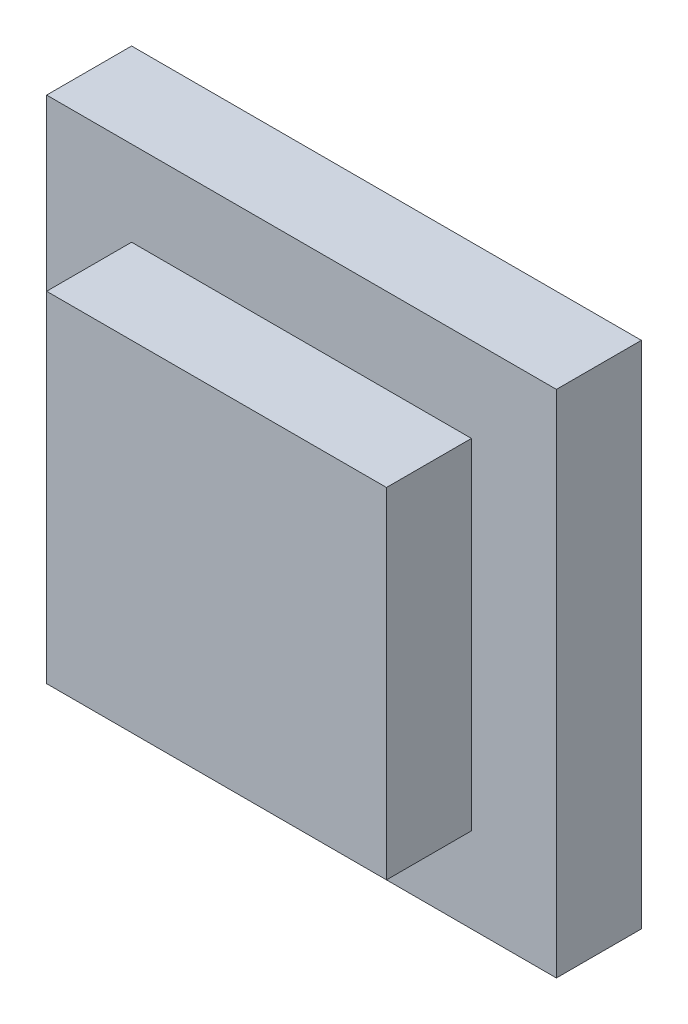
from build123d import *

# Parameters (mm, degrees)
SKETCH1_W     = 8
SKETCH1_H     = 8
NOTCH_DEPTH   = 4
SKETCH1_3_W   = 12
SKETCH1_3_H   = 12
SKETCH1_3_W_2 = 8
SKETCH1_3_H_2 = 8
BASE_DEPTH    = 2


with BuildPart() as part:
    # Sketch1 → Notch (new body)
    with BuildSketch(Plane.XY):
        Rectangle(SKETCH1_W, SKETCH1_H)
    extrude(amount=NOTCH_DEPTH)

    # Sketch1_3 → Base (add)
    with BuildSketch(Plane.XY):
        Rectangle(SKETCH1_3_W, SKETCH1_3_H)
        Rectangle(SKETCH1_3_W_2, SKETCH1_3_H_2, mode=Mode.SUBTRACT)
    extrude(amount=BASE_DEPTH)


solid = part.part
